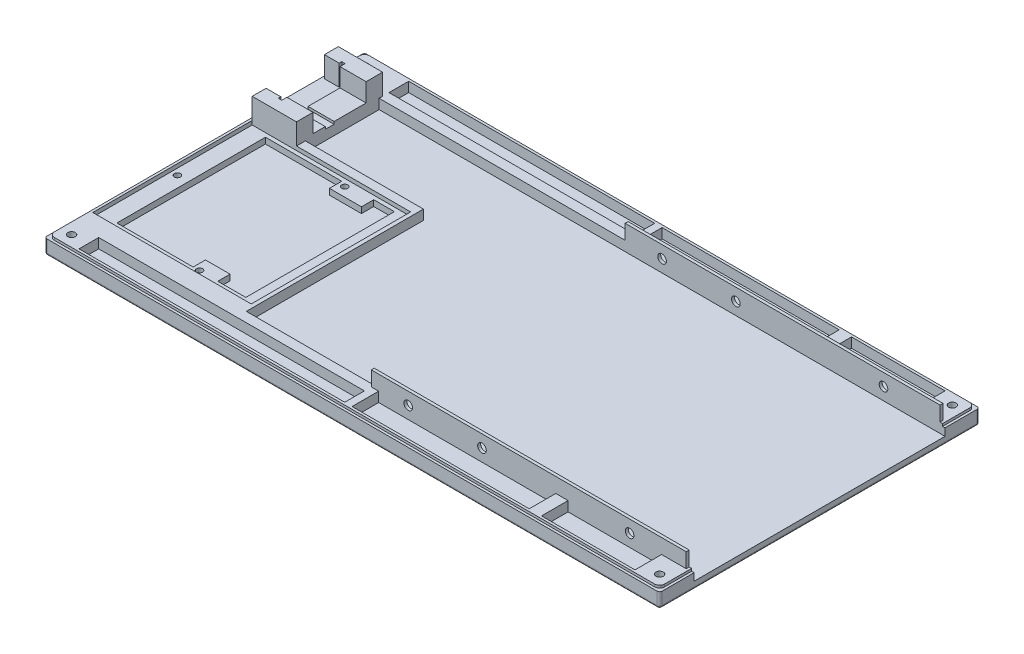
from build123d import *

# Parameters (mm, degrees)
SKETCH1_W                     = 250
SKETCH1_H                     = 130
BOSS_EXTRUDE1_DEPTH           = 3
SKETCH2_W                     = 250
SKETCH2_H                     = 1
BOSS_EXTRUDE2_DEPTH           = 6
SKETCH3_W                     = 250
SKETCH3_H                     = 1
BOSS_EXTRUDE3_DEPTH           = 3
SKETCH4_W                     = 1
SKETCH4_H                     = 128
BOSS_EXTRUDE4_DEPTH           = 3
SKETCH6_W                     = 1
SKETCH6_H                     = 14
BOSS_EXTRUDE5_DEPTH           = 3
SKETCH7_W                     = 1
SKETCH7_H                     = 14
BOSS_EXTRUDE6_DEPTH           = 3
SKETCH8_W                     = 1
SKETCH8_H                     = 13
BOSS_EXTRUDE7_DEPTH           = 4
SKETCH10_W                    = 247
SKETCH10_H                    = 1
BOSS_EXTRUDE8_DEPTH           = 4
SKETCH11_W                    = 1
SKETCH11_H                    = 127
BOSS_EXTRUDE9_DEPTH           = 4
SKETCH14_W                    = 247
SKETCH14_H                    = 1
BOSS_EXTRUDE10_DEPTH          = 4
SKETCH15_W                    = 1
SKETCH15_H                    = 12
BOSS_EXTRUDE11_DEPTH          = 4
FILLET1_R                     = 1
SKETCH17_W                    = 128
SKETCH17_H                    = 1.2
BOSS_EXTRUDE12_DEPTH          = 10
SKETCH19_W                    = 128
SKETCH19_H                    = 1.2
BOSS_EXTRUDE13_DEPTH          = 10
SKETCH22_W                    = 3
SKETCH22_H                    = 10.8
BOSS_EXTRUDE14_DEPTH          = 4
SKETCH24_W                    = 3
SKETCH24_H                    = 10.8
BOSS_EXTRUDE15_DEPTH          = 4
FLOPPYMOUNTHOLE001_REACH      = 16
SKETCH25_R                    = 1.75
FLOPPYMOUNTHOLE002_REACH      = 16
SKETCH26_R                    = 1.75
FLOPPYMOUNTHOLE003_REACH      = 16
SKETCH27_R                    = 1.75
FLOPPYMOUNTHOLE004_REACH      = 119.2
SKETCH28_R                    = 1.75
FLOPPYMOUNTHOLE005_REACH      = 119.2
SKETCH29_R                    = 1.75
FLOPPYMOUNTHOLE006_REACH      = 119.2
SKETCH30_R                    = 1.75
SKETCH31_W                    = 5
SKETCH31_H                    = 10.8
BOSS_EXTRUDE16_DEPTH          = 4
SKETCH33_W                    = 5
SKETCH33_H                    = 10.8
BOSS_EXTRUDE18_DEPTH          = 4
FILLET2_R                     = 2
SKETCH35_W                    = 66
SKETCH35_H                    = 3.6
GWOUTER001_DEPTH              = 4
SKETCH36_W                    = 1.6
SKETCH36_H                    = 64.8
GWOUTER002_DEPTH              = 4
SKETCH37_W                    = 66
SKETCH37_H                    = 3.6
GWOUTER003_DEPTH              = 4
SKETCH38_W                    = 7
SKETCH38_H                    = 64.8
GWSUPPORTBACK_DEPTH           = 2.4
SKETCH39_W                    = 5
SKETCH39_H                    = 64.8
GWSUPPORTFRT_DEPTH            = 2.4
SKETCH40_W                    = 52.4
SKETCH40_H                    = 1.6
GWSUPPORTLT_DEPTH             = 2.4
SKETCH41_W                    = 52.4
SKETCH41_H                    = 2.8
GWSUPPORTRT_DEPTH             = 2.4
SKETCH43_W                    = 10
SKETCH43_H                    = 5
GWSCREWRT_DEPTH               = 2.4
SKETCH44_W                    = 118
SKETCH44_H                    = 4
BOSS_EXTRUDE28_DEPTH          = 4
SKETCH45_W                    = 18
SKETCH45_H                    = 42
BOSS_EXTRUDE29_DEPTH          = 4
SKETCH46_W                    = 10
SKETCH46_H                    = 8
BOSS_EXTRUDE30_DEPTH          = 4
SKETCH47_W                    = 10
SKETCH47_H                    = 10.8
BOSS_EXTRUDE31_DEPTH          = 4
SKETCH48_W                    = 10
SKETCH48_H                    = 10.8
BOSS_EXTRUDE32_DEPTH          = 4
SKETCH49_W                    = 100
SKETCH49_H                    = 4
BOSS_EXTRUDE33_DEPTH          = 4
SKETCH50_W                    = 13
SKETCH50_H                    = 5
GWSCREWLT_DEPTH               = 2.4
SKETCH51_R                    = 1.25
GWLSIDEMOUNTHOLE_DEPTH        = 5
SKETCH52_R                    = 1.25
GWRSIDEMOUNTHOLE_DEPTH        = 5
SKETCH53_R                    = 1.25
GWBACKMOUNTHOLE_DEPTH         = 5
SKETCH54_W                    = 6
SKETCH54_H                    = 5.65
MOLEX001_DEPTH                = 8.5
SKETCH55_W                    = 6
SKETCH55_H                    = 5.65
MOLEX002_DEPTH                = 8.5
SKETCH56_W                    = 1.4
SKETCH56_H                    = 4.6
MOLEX003_DEPTH                = 8.5
SKETCH57_W                    = 1.4
SKETCH57_H                    = 4.6
MOLEX004_DEPTH                = 8.5
SKETCH58_W                    = 10.6
SKETCH58_H                    = 6.7
MOLEX005_DEPTH                = 8.5
SKETCH59_W                    = 10.6
SKETCH59_H                    = 6.7
MOLEX006_DEPTH                = 8.5
SKETCH60_W                    = 10.6
SKETCH60_H                    = 13
MOLEX007_DEPTH                = 1
SKETCH61_W                    = 10.6
SKETCH61_H                    = 5
MOLEX008_DEPTH                = 1
SKETCH62_R                    = 1.5
CASEMUNTHOLE001_DEPTH         = 8
SKETCH63_R                    = 1.5
CASEMUNTHOLE002_DEPTH         = 8
SKETCH64_R                    = 1.5
CASEMUNTHOLE003_DEPTH         = 8
SKETCH65_R                    = 1.5
CASEMUNTHOLE004_DEPTH         = 8
CASEMOUNTHOLECOUNTERSINK_SIZE = 2


with BuildPart() as part:
    # Sketch1 → Boss-Extrude1 (new body)
    with BuildSketch(Plane(origin=(0, 0, 0), x_dir=(1, 0, 0), z_dir=(0, 1, 0))):
        Rectangle(SKETCH1_W, SKETCH1_H)
    extrude(amount=BOSS_EXTRUDE1_DEPTH)

    # Sketch2 → Boss-Extrude2 (add)
    with BuildSketch(Plane(origin=(0, 0, 0), x_dir=(1, 0, 0), z_dir=(0, 1, 0))):
        with Locations((0, 64.5)):
            Rectangle(SKETCH2_W, SKETCH2_H)
    extrude(amount=BOSS_EXTRUDE2_DEPTH)

    # Sketch3 → Boss-Extrude3 (add)
    with BuildSketch(Plane(origin=(0, 3, 0), x_dir=(1, 0, 0), z_dir=(0, 1, 0))):
        with Locations((0, -64.5)):
            Rectangle(SKETCH3_W, SKETCH3_H)
    extrude(amount=BOSS_EXTRUDE3_DEPTH)

    # Sketch4 → Boss-Extrude4 (add)
    with BuildSketch(Plane(origin=(0, 3, 0), x_dir=(1, 0, 0), z_dir=(0, 1, 0))):
        with Locations((-124.5, 0)):
            Rectangle(SKETCH4_W, SKETCH4_H)
    extrude(amount=BOSS_EXTRUDE4_DEPTH)

    # Sketch6 → Boss-Extrude5 (add)
    with BuildSketch(Plane(origin=(0, 3, 0), x_dir=(1, 0, 0), z_dir=(0, 1, 0))):
        with Locations((124.5, -58)):
            Rectangle(SKETCH6_W, SKETCH6_H)
    extrude(amount=BOSS_EXTRUDE5_DEPTH)

    # Sketch7 → Boss-Extrude6 (add)
    with BuildSketch(Plane(origin=(0, 3, 0), x_dir=(1, 0, 0), z_dir=(0, 1, 0))):
        with Locations((124.5, 58)):
            Rectangle(SKETCH7_W, SKETCH7_H)
    extrude(amount=BOSS_EXTRUDE6_DEPTH)

    # Sketch8 → Boss-Extrude7 (add)
    with BuildSketch(Plane(origin=(0, 3, 0), x_dir=(1, 0, 0), z_dir=(0, 1, 0))):
        with Locations((123.5, 57.5)):
            Rectangle(SKETCH8_W, SKETCH8_H)
    extrude(amount=BOSS_EXTRUDE7_DEPTH)

    # Sketch10 → Boss-Extrude8 (add)
    with BuildSketch(Plane(origin=(0, 3, 0), x_dir=(1, 0, 0), z_dir=(0, 1, 0))):
        with Locations((-0.5, 63.5)):
            Rectangle(SKETCH10_W, SKETCH10_H)
    extrude(amount=BOSS_EXTRUDE8_DEPTH)

    # Sketch11 → Boss-Extrude9 (add)
    with BuildSketch(Plane(origin=(0, 3, 0), x_dir=(1, 0, 0), z_dir=(0, 1, 0))):
        with Locations((-123.5, -0.5)):
            Rectangle(SKETCH11_W, SKETCH11_H)
    extrude(amount=BOSS_EXTRUDE9_DEPTH)

    # Sketch14 → Boss-Extrude10 (add)
    with BuildSketch(Plane(origin=(0, 3, 0), x_dir=(1, 0, 0), z_dir=(0, 1, 0))):
        with Locations((0.5, -63.5)):
            Rectangle(SKETCH14_W, SKETCH14_H)
    extrude(amount=BOSS_EXTRUDE10_DEPTH)

    # Sketch15 → Boss-Extrude11 (add)
    with BuildSketch(Plane(origin=(0, 3, 0), x_dir=(1, 0, 0), z_dir=(0, 1, 0))):
        with Locations((123.5, -57)):
            Rectangle(SKETCH15_W, SKETCH15_H)
    extrude(amount=BOSS_EXTRUDE11_DEPTH)

    # Fillet1
    fillet1_edges = [part.edges().sort_by_distance(p)[0] for p in [
        (0, 0, 65),
        (-125, 0, 0),
        (0, 0, -65),
        (125, 0, 0),
        (125, 3, 65),
        (-125, 3, 65),
        (-125, 3, -65),
        (125, 3, -65),
    ]]
    fillet(fillet1_edges, radius=FILLET1_R)

    # Sketch17 → Boss-Extrude12 (add)
    with BuildSketch(Plane(origin=(0, 3, 0), x_dir=(1, 0, 0), z_dir=(0, 1, 0))):
        with Locations((59, 51.6)):
            Rectangle(SKETCH17_W, SKETCH17_H)
    extrude(amount=BOSS_EXTRUDE12_DEPTH)

    # Sketch19 → Boss-Extrude13 (add)
    with BuildSketch(Plane(origin=(0, 3, 0), x_dir=(1, 0, 0), z_dir=(0, 1, 0))):
        with Locations((59, -51.6)):
            Rectangle(SKETCH19_W, SKETCH19_H)
    extrude(amount=BOSS_EXTRUDE13_DEPTH)

    # Sketch22 → Boss-Extrude14 (add)
    with BuildSketch(Plane(origin=(0, 3, 0), x_dir=(1, 0, 0), z_dir=(0, 1, 0))):
        with Locations((-3.5, -57.6)):
            Rectangle(SKETCH22_W, SKETCH22_H)
    extrude(amount=BOSS_EXTRUDE14_DEPTH)

    # Sketch24 → Boss-Extrude15 (add)
    with BuildSketch(Plane(origin=(0, 3, 0), x_dir=(1, 0, 0), z_dir=(0, 1, 0))):
        with Locations((-3.5, 57.6)):
            Rectangle(SKETCH24_W, SKETCH24_H)
    extrude(amount=BOSS_EXTRUDE15_DEPTH)

    # Sketch25 → FloppyMountHole001 (cut, up to next)
    with BuildSketch(Plane.XY.offset(-51), mode=Mode.PRIVATE) as floppymounthole001_sk1:
        with Locations((100, 8)):
            Circle(SKETCH25_R)
    floppymounthole001_tool1 = extrude(floppymounthole001_sk1.sketch, amount=-FLOPPYMOUNTHOLE001_REACH, mode=Mode.PRIVATE) & part.part
    add(floppymounthole001_tool1.solids().sort_by_distance((100, 8, -51))[0], mode=Mode.SUBTRACT)

    # Sketch26 → FloppyMountHole002 (cut, up to next)
    with BuildSketch(Plane.XY.offset(-51), mode=Mode.PRIVATE) as floppymounthole002_sk1:
        with Locations((40, 8)):
            Circle(SKETCH26_R)
    floppymounthole002_tool1 = extrude(floppymounthole002_sk1.sketch, amount=-FLOPPYMOUNTHOLE002_REACH, mode=Mode.PRIVATE) & part.part
    add(floppymounthole002_tool1.solids().sort_by_distance((40, 8, -51))[0], mode=Mode.SUBTRACT)

    # Sketch27 → FloppyMountHole003 (cut, up to next)
    with BuildSketch(Plane.XY.offset(-51), mode=Mode.PRIVATE) as floppymounthole003_sk1:
        with Locations((10, 8)):
            Circle(SKETCH27_R)
    floppymounthole003_tool1 = extrude(floppymounthole003_sk1.sketch, amount=-FLOPPYMOUNTHOLE003_REACH, mode=Mode.PRIVATE) & part.part
    add(floppymounthole003_tool1.solids().sort_by_distance((10, 8, -51))[0], mode=Mode.SUBTRACT)

    # Sketch28 → FloppyMountHole004 (cut, up to next)
    with BuildSketch(Plane.XY.offset(52.2), mode=Mode.PRIVATE) as floppymounthole004_sk1:
        with Locations((100, 8)):
            Circle(SKETCH28_R)
    floppymounthole004_tool1 = extrude(floppymounthole004_sk1.sketch, amount=-FLOPPYMOUNTHOLE004_REACH, mode=Mode.PRIVATE) & part.part
    add(floppymounthole004_tool1.solids().sort_by_distance((100, 8, 52.2))[0], mode=Mode.SUBTRACT)

    # Sketch29 → FloppyMountHole005 (cut, up to next)
    with BuildSketch(Plane.XY.offset(52.2), mode=Mode.PRIVATE) as floppymounthole005_sk1:
        with Locations((40, 8)):
            Circle(SKETCH29_R)
    floppymounthole005_tool1 = extrude(floppymounthole005_sk1.sketch, amount=-FLOPPYMOUNTHOLE005_REACH, mode=Mode.PRIVATE) & part.part
    add(floppymounthole005_tool1.solids().sort_by_distance((40, 8, 52.2))[0], mode=Mode.SUBTRACT)

    # Sketch30 → FloppyMountHole006 (cut, up to next)
    with BuildSketch(Plane.XY.offset(52.2), mode=Mode.PRIVATE) as floppymounthole006_sk1:
        with Locations((10, 8)):
            Circle(SKETCH30_R)
    floppymounthole006_tool1 = extrude(floppymounthole006_sk1.sketch, amount=-FLOPPYMOUNTHOLE006_REACH, mode=Mode.PRIVATE) & part.part
    add(floppymounthole006_tool1.solids().sort_by_distance((10, 8, 52.2))[0], mode=Mode.SUBTRACT)

    # Sketch31 → Boss-Extrude16 (add)
    with BuildSketch(Plane(origin=(0, 3, 0), x_dir=(1, 0, 0), z_dir=(0, 1, 0))):
        with Locations((72.5, -57.6)):
            Rectangle(SKETCH31_W, SKETCH31_H)
    extrude(amount=BOSS_EXTRUDE16_DEPTH)

    # Sketch33 → Boss-Extrude18 (add)
    with BuildSketch(Plane(origin=(0, 3, 0), x_dir=(1, 0, 0), z_dir=(0, 1, 0))):
        with Locations((72.5, 57.6)):
            Rectangle(SKETCH33_W, SKETCH33_H)
    extrude(amount=BOSS_EXTRUDE18_DEPTH)

    # Fillet2
    fillet2_edges = [part.edges().sort_by_distance(p)[0] for p in [
        (124, 6.5, -64),
        (-124, 6.5, -64),
        (-124, 6.5, 64),
        (124, 6.5, 64),
    ]]
    fillet(fillet2_edges, radius=FILLET2_R)

    # Sketch35 → GWOuter001 (add)
    with BuildSketch(Plane(origin=(0, 3, 0), x_dir=(1, 0, 0), z_dir=(0, 1, 0))):
        with Locations((-90, -49.2)):
            Rectangle(SKETCH35_W, SKETCH35_H)
    extrude(amount=GWOUTER001_DEPTH)

    # Sketch36 → GWOuter002 (add)
    with BuildSketch(Plane(origin=(0, 3, 0), x_dir=(1, 0, 0), z_dir=(0, 1, 0))):
        with Locations((-57.8, -15)):
            Rectangle(SKETCH36_W, SKETCH36_H)
    extrude(amount=GWOUTER002_DEPTH)

    # Sketch37 → GWOuter003 (add)
    with BuildSketch(Plane(origin=(0, 3, 0), x_dir=(1, 0, 0), z_dir=(0, 1, 0))):
        with Locations((-90, 19.2)):
            Rectangle(SKETCH37_W, SKETCH37_H)
    extrude(amount=GWOUTER003_DEPTH)

    # Sketch38 → GWSupportBack (add)
    with BuildSketch(Plane(origin=(0, 3, 0), x_dir=(1, 0, 0), z_dir=(0, 1, 0))):
        with Locations((-119.5, -15)):
            Rectangle(SKETCH38_W, SKETCH38_H)
    extrude(amount=GWSUPPORTBACK_DEPTH)

    # Sketch39 → GWSupportFrt (add)
    with BuildSketch(Plane(origin=(0, 3, 0), x_dir=(1, 0, 0), z_dir=(0, 1, 0))):
        with Locations((-61.1, -15)):
            Rectangle(SKETCH39_W, SKETCH39_H)
    extrude(amount=GWSUPPORTFRT_DEPTH)

    # Sketch40 → GWSupportLt (add)
    with BuildSketch(Plane(origin=(0, 3, 0), x_dir=(1, 0, 0), z_dir=(0, 1, 0))):
        with Locations((-89.8, 16.6)):
            Rectangle(SKETCH40_W, SKETCH40_H)
    extrude(amount=GWSUPPORTLT_DEPTH)

    # Sketch41 → GWSupportRt (add)
    with BuildSketch(Plane(origin=(0, 3, 0), x_dir=(1, 0, 0), z_dir=(0, 1, 0))):
        with Locations((-89.8, -46)):
            Rectangle(SKETCH41_W, SKETCH41_H)
    extrude(amount=GWSUPPORTRT_DEPTH)

    # Sketch43 → GWScrewRt (add)
    with BuildSketch(Plane(origin=(0, 3, 0), x_dir=(1, 0, 0), z_dir=(0, 1, 0))):
        with Locations((-80, -42.1)):
            Rectangle(SKETCH43_W, SKETCH43_H)
    extrude(amount=GWSCREWRT_DEPTH)

    # Sketch44 → Boss-Extrude28 (add)
    with BuildSketch(Plane(origin=(0, 3, 0), x_dir=(1, 0, 0), z_dir=(0, 1, 0))):
        with Locations((-64, -53)):
            Rectangle(SKETCH44_W, SKETCH44_H)
    extrude(amount=BOSS_EXTRUDE28_DEPTH)

    # Sketch45 → Boss-Extrude29 (add)
    with BuildSketch(Plane(origin=(0, 3, 0), x_dir=(1, 0, 0), z_dir=(0, 1, 0))):
        with Locations((-114, 42)):
            Rectangle(SKETCH45_W, SKETCH45_H)
    extrude(amount=BOSS_EXTRUDE29_DEPTH)

    # Sketch46 → Boss-Extrude30 (add)
    with BuildSketch(Plane(origin=(0, 3, 0), x_dir=(1, 0, 0), z_dir=(0, 1, 0))):
        with Locations((-118, -59)):
            Rectangle(SKETCH46_W, SKETCH46_H)
    extrude(amount=BOSS_EXTRUDE30_DEPTH)

    # Sketch47 → Boss-Extrude31 (add)
    with BuildSketch(Plane(origin=(0, 3, 0), x_dir=(1, 0, 0), z_dir=(0, 1, 0))):
        with Locations((118, 57.6)):
            Rectangle(SKETCH47_W, SKETCH47_H)
    extrude(amount=BOSS_EXTRUDE31_DEPTH)

    # Sketch48 → Boss-Extrude32 (add)
    with BuildSketch(Plane(origin=(0, 3, 0), x_dir=(1, 0, 0), z_dir=(0, 1, 0))):
        with Locations((118, -57.6)):
            Rectangle(SKETCH48_W, SKETCH48_H)
    extrude(amount=BOSS_EXTRUDE32_DEPTH)

    # Sketch49 → Boss-Extrude33 (add)
    with BuildSketch(Plane(origin=(0, 3, 0), x_dir=(1, 0, 0), z_dir=(0, 1, 0))):
        with Locations((-55, 53)):
            Rectangle(SKETCH49_W, SKETCH49_H)
    extrude(amount=BOSS_EXTRUDE33_DEPTH)

    # Sketch50 → GWScrewLt (add)
    with BuildSketch(Plane(origin=(0, 3, 0), x_dir=(1, 0, 0), z_dir=(0, 1, 0))):
        with Locations((-78.5, 13.3)):
            Rectangle(SKETCH50_W, SKETCH50_H)
    extrude(amount=GWSCREWLT_DEPTH)

    # Sketch51 → GWLSideMountHole (cut)
    with BuildSketch(Plane(origin=(0, 5.4, 0), x_dir=(1, 0, 0), z_dir=(0, 1, 0))):
        with Locations((-82.5, 14.5)):
            Circle(SKETCH51_R)
    extrude(amount=-GWLSIDEMOUNTHOLE_DEPTH, mode=Mode.SUBTRACT)

    # Sketch52 → GWRSideMountHole (cut)
    with BuildSketch(Plane(origin=(0, 5.4, 0), x_dir=(1, 0, 0), z_dir=(0, 1, 0))):
        with Locations((-82.5, -44.5)):
            Circle(SKETCH52_R)
    extrude(amount=-GWRSIDEMOUNTHOLE_DEPTH, mode=Mode.SUBTRACT)

    # Sketch53 → GWBackMountHole (cut)
    with BuildSketch(Plane(origin=(0, 5.4, 0), x_dir=(1, 0, 0), z_dir=(0, 1, 0))):
        with Locations((-120.5, -15.5)):
            Circle(SKETCH53_R)
    extrude(amount=-GWBACKMOUNTHOLE_DEPTH, mode=Mode.SUBTRACT)

    # Sketch54 → Molex001 (add)
    with BuildSketch(Plane(origin=(0, 7, 0), x_dir=(1, 0, 0), z_dir=(0, 1, 0))):
        with Locations((-120, 20.225)):
            Rectangle(SKETCH54_W, SKETCH54_H)
    extrude(amount=MOLEX001_DEPTH)

    # Sketch55 → Molex002 (add)
    with BuildSketch(Plane(origin=(0, 7, 0), x_dir=(1, 0, 0), z_dir=(0, 1, 0))):
        with Locations((-120, 49.575)):
            Rectangle(SKETCH55_W, SKETCH55_H)
    extrude(amount=MOLEX002_DEPTH)

    # Sketch56 → Molex003 (add)
    with BuildSketch(Plane(origin=(0, 7, 0), x_dir=(1, 0, 0), z_dir=(0, 1, 0))):
        with Locations((-116.3, 19.7)):
            Rectangle(SKETCH56_W, SKETCH56_H)
    extrude(amount=MOLEX003_DEPTH)

    # Sketch57 → Molex004 (add)
    with BuildSketch(Plane(origin=(0, 7, 0), x_dir=(1, 0, 0), z_dir=(0, 1, 0))):
        with Locations((-116.3, 50.1)):
            Rectangle(SKETCH57_W, SKETCH57_H)
    extrude(amount=MOLEX004_DEPTH)

    # Sketch58 → Molex005 (add)
    with BuildSketch(Plane(origin=(0, 7, 0), x_dir=(1, 0, 0), z_dir=(0, 1, 0))):
        with Locations((-110.3, 49.05)):
            Rectangle(SKETCH58_W, SKETCH58_H)
    extrude(amount=MOLEX005_DEPTH)

    # Sketch59 → Molex006 (add)
    with BuildSketch(Plane(origin=(0, 7, 0), x_dir=(1, 0, 0), z_dir=(0, 1, 0))):
        with Locations((-110.3, 20.75)):
            Rectangle(SKETCH59_W, SKETCH59_H)
    extrude(amount=MOLEX006_DEPTH)

    # Sketch60 → Molex007 (add)
    with BuildSketch(Plane(origin=(0, 7, 0), x_dir=(1, 0, 0), z_dir=(0, 1, 0))):
        with Locations((-110.3, 39.2)):
            Rectangle(SKETCH60_W, SKETCH60_H)
    extrude(amount=MOLEX007_DEPTH)

    # Sketch61 → Molex008 (add)
    with BuildSketch(Plane(origin=(0, 7, 0), x_dir=(1, 0, 0), z_dir=(0, 1, 0))):
        with Locations((-110.3, 26.6)):
            Rectangle(SKETCH61_W, SKETCH61_H)
    extrude(amount=MOLEX008_DEPTH)

    # Sketch62 → CaseMuntHole001 (cut, through all)
    with BuildSketch(Plane(origin=(0, 7, 0), x_dir=(1, 0, 0), z_dir=(0, 1, 0))):
        with Locations((-119.5, 59.5)):
            Circle(SKETCH62_R)
    extrude(amount=-CASEMUNTHOLE001_DEPTH, mode=Mode.SUBTRACT)

    # Sketch63 → CaseMuntHole002 (cut, through all)
    with BuildSketch(Plane(origin=(0, 7, 0), x_dir=(1, 0, 0), z_dir=(0, 1, 0))):
        with Locations((119.5, 59.5)):
            Circle(SKETCH63_R)
    extrude(amount=-CASEMUNTHOLE002_DEPTH, mode=Mode.SUBTRACT)

    # Sketch64 → CaseMuntHole003 (cut, through all)
    with BuildSketch(Plane(origin=(0, 7, 0), x_dir=(1, 0, 0), z_dir=(0, 1, 0))):
        with Locations((119.5, -59.5)):
            Circle(SKETCH64_R)
    extrude(amount=-CASEMUNTHOLE003_DEPTH, mode=Mode.SUBTRACT)

    # Sketch65 → CaseMuntHole004 (cut, through all)
    with BuildSketch(Plane(origin=(0, 7, 0), x_dir=(1, 0, 0), z_dir=(0, 1, 0))):
        with Locations((-119.5, -59.5)):
            Circle(SKETCH65_R)
    extrude(amount=-CASEMUNTHOLE004_DEPTH, mode=Mode.SUBTRACT)

    # CaseMountHoleCountersink
    casemountholecountersink_edges = [part.edges().sort_by_distance(p)[0] for p in [
        (-121, 0, -59.5),
        (118, 0, -59.5),
        (118, 0, 59.5),
        (-121, 0, 59.5),
    ]]
    chamfer(casemountholecountersink_edges, length=CASEMOUNTHOLECOUNTERSINK_SIZE)


solid = part.part
